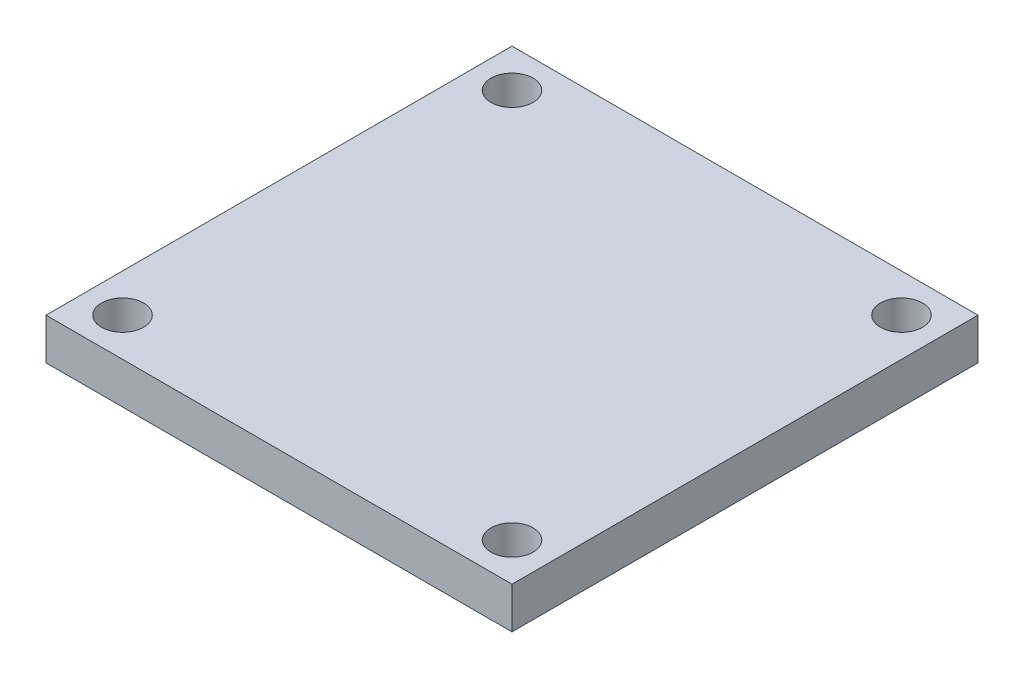
from build123d import *

# Parameters (mm, degrees)
SKETCH1_W           = 56.4
SKETCH1_H           = 56.4
SKETCH1_R           = 2.55
BOSS_EXTRUDE1_DEPTH = 5


with BuildPart() as part:
    # Sketch1 → Boss-Extrude1 (new body)
    with BuildSketch(Plane(origin=(0, 0, 0), x_dir=(1, 0, 0), z_dir=(0, 1, 0))):
        Rectangle(SKETCH1_W, SKETCH1_H)
        with Locations((-23.57, -23.57)):
            Circle(SKETCH1_R, mode=Mode.SUBTRACT)
        with Locations((23.57, -23.57)):
            Circle(SKETCH1_R, mode=Mode.SUBTRACT)
        with Locations((23.57, 23.57)):
            Circle(SKETCH1_R, mode=Mode.SUBTRACT)
        with Locations((-23.57, 23.57)):
            Circle(SKETCH1_R, mode=Mode.SUBTRACT)
    extrude(amount=BOSS_EXTRUDE1_DEPTH)


solid = part.part
